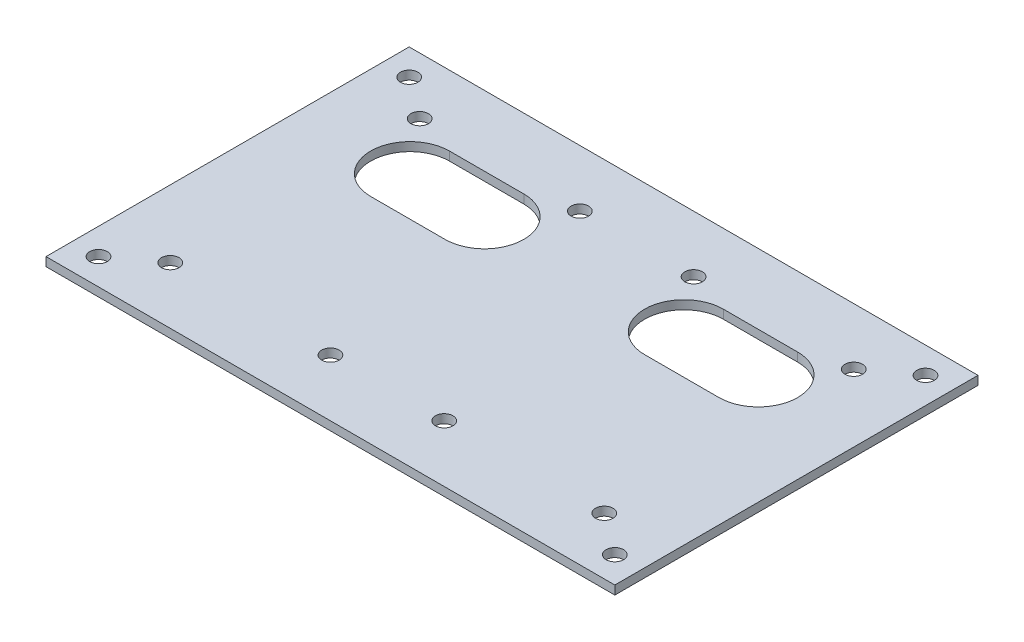
from build123d import *

# Parameters (mm, degrees)
SKETCH1_W           = 130
SKETCH1_H           = 83
SKETCH1_R           = 2
BOSS_EXTRUDE1_DEPTH = 2


with BuildPart() as part:
    # Sketch1 → Boss-Extrude1 (new body)
    with BuildSketch(Plane(origin=(0, 0, 0), x_dir=(1, 0, 0), z_dir=(0, 1, 0))):
        Rectangle(SKETCH1_W, SKETCH1_H)
        with Locations((13, 28.5)):
            Circle(SKETCH1_R, mode=Mode.SUBTRACT)
        with Locations((49.6, 28.5)):
            Circle(SKETCH1_R, mode=Mode.SUBTRACT)
        with Locations((49.6, -28.5)):
            Circle(SKETCH1_R, mode=Mode.SUBTRACT)
        with Locations((13, -28.5)):
            Circle(SKETCH1_R, mode=Mode.SUBTRACT)
        with Locations((-13, -28.5)):
            Circle(SKETCH1_R, mode=Mode.SUBTRACT)
        with Locations((-49.6, -28.5)):
            Circle(SKETCH1_R, mode=Mode.SUBTRACT)
        with Locations((-49.6, 28.5)):
            Circle(SKETCH1_R, mode=Mode.SUBTRACT)
        with Locations((-13, 28.5)):
            Circle(SKETCH1_R, mode=Mode.SUBTRACT)
        with Locations((-59, 35.5)):
            Circle(SKETCH1_R, mode=Mode.SUBTRACT)
        with Locations((59, 35.5)):
            Circle(SKETCH1_R, mode=Mode.SUBTRACT)
        with Locations((59, -35.5)):
            Circle(SKETCH1_R, mode=Mode.SUBTRACT)
        with Locations((-59, -35.5)):
            Circle(SKETCH1_R, mode=Mode.SUBTRACT)
        with BuildLine():
            Line((22.8, 25.5), (39.8, 25.5))
            ThreePointArc((39.8, 25.5), (48.8, 16.5), (39.8, 7.5))
            Line((39.8, 7.5), (22.8, 7.5))
            ThreePointArc((22.8, 7.5), (13.8, 16.5), (22.8, 25.5))
        make_face(mode=Mode.SUBTRACT)
        with BuildLine():
            Line((-22.8, 25.5), (-39.8, 25.5))
            ThreePointArc((-39.8, 25.5), (-48.8, 16.5), (-39.8, 7.5))
            Line((-39.8, 7.5), (-22.8, 7.5))
            ThreePointArc((-22.8, 7.5), (-13.8, 16.5), (-22.8, 25.5))
        make_face(mode=Mode.SUBTRACT)
    extrude(amount=BOSS_EXTRUDE1_DEPTH)


solid = part.part
